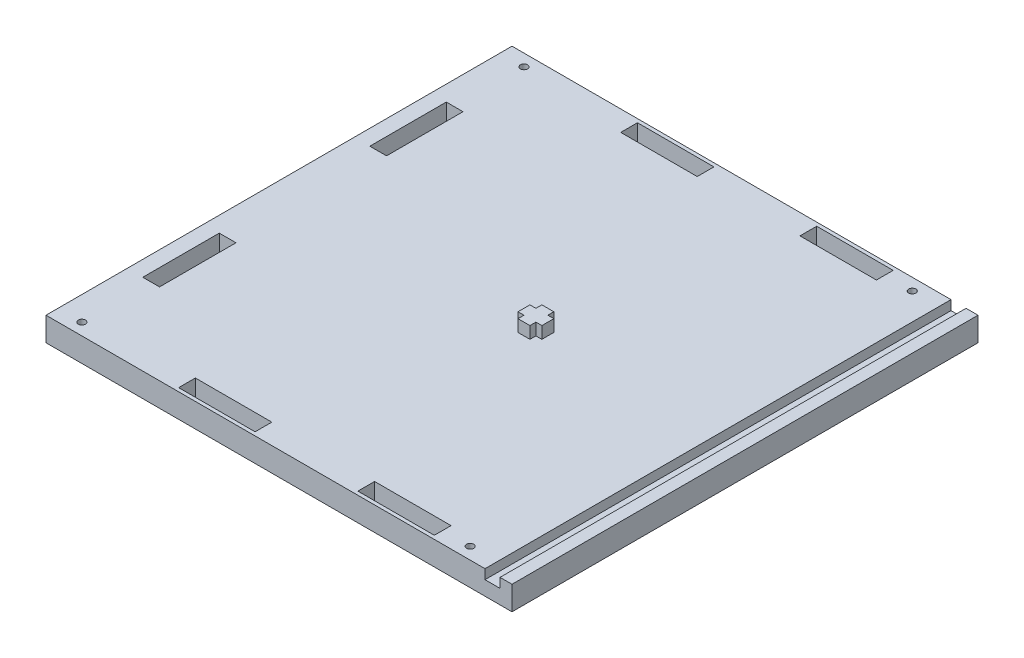
from build123d import *

# Parameters (mm, degrees)
ESBO_O1_W                = 195
ESBO_O1_H                = 195
RESSALTO_EXTRUS_O1_DEPTH = 10
ESBO_O2_W                = 7
ESBO_O2_H                = 32
ESBO_O2_W_2              = 32
ESBO_O2_H_2              = 7
CORTE_EXTRUS_O1_DEPTH    = 11
ESBO_O3_W                = 6.3
ESBO_O3_H                = 195
CORTE_EXTRUS_O2_DEPTH    = 4
ESBO_O4_R                = 1.5
CORTE_EXTRUS_O3_DEPTH    = 11
ESBO_O5_R                = 1.5
CORTE_EXTRUS_O4_DEPTH    = 11
ESBO_O6_W                = 5
ESBO_O6_H                = 2.5
ESBO_O6_H_2              = 5
ESBO_O6_W_2              = 2.5
RESSALTO_EXTRUS_O2_DEPTH = 5


with BuildPart() as part:
    # Esboço1 → Ressalto-extrusão1 (new body)
    with BuildSketch(Plane(origin=(0, 0, 0), x_dir=(1, 0, 0), z_dir=(0, 1, 0))):
        Rectangle(ESBO_O1_W, ESBO_O1_H)
    extrude(amount=RESSALTO_EXTRUS_O1_DEPTH)

    # Esboço2 → Corte-extrusão1 (cut, through all)
    with BuildSketch(Plane(origin=(0, 10, 0), x_dir=(1, 0, 0), z_dir=(0, 1, 0))):
        with Locations((-87.5, 47.5)):
            Rectangle(ESBO_O2_W, ESBO_O2_H)
        with Locations((-87.5, -47.5)):
            Rectangle(ESBO_O2_W, ESBO_O2_H)
        with Locations((-27.5, -92.5)):
            Rectangle(ESBO_O2_W_2, ESBO_O2_H_2)
        with Locations((47.5, -92.5)):
            Rectangle(ESBO_O2_W_2, ESBO_O2_H_2)
        with Locations((47.5, 92.5)):
            Rectangle(ESBO_O2_W_2, ESBO_O2_H_2)
        with Locations((-27.5, 92.5)):
            Rectangle(ESBO_O2_W_2, ESBO_O2_H_2)
    extrude(amount=-CORTE_EXTRUS_O1_DEPTH, mode=Mode.SUBTRACT)

    # Esboço3 → Corte-extrusão2 (cut)
    with BuildSketch(Plane(origin=(0, 10, 0), x_dir=(1, 0, 0), z_dir=(0, 1, 0))):
        with Locations((89.35, 0)):
            Rectangle(ESBO_O3_W, ESBO_O3_H)
    extrude(amount=-CORTE_EXTRUS_O2_DEPTH, mode=Mode.SUBTRACT)

    # Esboço4 → Corte-extrusão3 (cut, through all)
    with BuildSketch(Plane.XZ):
        with Locations((-87.5, 92.5)):
            Circle(ESBO_O4_R)
        with Locations((-87.5, -92.5)):
            Circle(ESBO_O4_R)
    extrude(amount=-CORTE_EXTRUS_O3_DEPTH, mode=Mode.SUBTRACT)

    # Esboço5 → Corte-extrusão4 (cut, through all)
    with BuildSketch(Plane.XZ):
        with Locations((75, 92.5)):
            Circle(ESBO_O5_R)
        with Locations((75, -92.5)):
            Circle(ESBO_O5_R)
    extrude(amount=-CORTE_EXTRUS_O4_DEPTH, mode=Mode.SUBTRACT)

    # Esboço6 → Ressalto-extrusão2 (add)
    with BuildSketch(Plane(origin=(0, 10, 0), x_dir=(1, 0, 0), z_dir=(0, 1, 0))):
        with Locations((10, -3.75)):
            Rectangle(ESBO_O6_W, ESBO_O6_H)
        with Locations((10, 0)):
            Rectangle(ESBO_O6_W, ESBO_O6_H_2)
        with Locations((13.75, 0)):
            Rectangle(ESBO_O6_W_2, ESBO_O6_H_2)
        with Locations((6.25, 0)):
            Rectangle(ESBO_O6_W_2, ESBO_O6_H_2)
        with Locations((10, 3.75)):
            Rectangle(ESBO_O6_W, ESBO_O6_H)
    extrude(amount=RESSALTO_EXTRUS_O2_DEPTH)


solid = part.part
